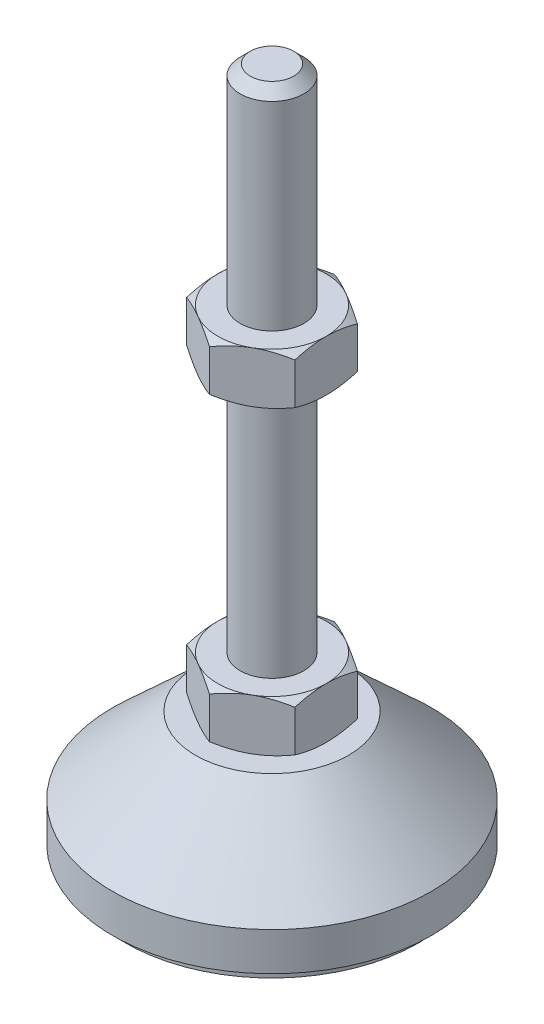
from build123d import *

# Parameters (mm, degrees)
EXTRUDE_1_DEPTH = 8
EXTRUDE_2_DEPTH = 8


with BuildPart() as part:
    # Эскиз1 → Повернуть1 (revolve)
    with BuildSketch(Plane.XY, mode=Mode.PRIVATE) as revolve_1_sk:
        Polygon((0, 0), (-23, 0), (-23, 2), (-25, 2), (-25, 8), (-12, 20), (-5, 20), (-5, 28), (-5, 106.4), (-3.4, 108), (0, 108), align=None)
    revolve(revolve_1_sk.sketch.rotate(Axis((0, 0, 0), (0, 1, 0)), 180), axis=Axis((0, 0, 0), (0, 1, 0)))  # turned: the seam where the file's is

    # Эскиз2 → Бобышка-Вытянуть1 (add)
    with BuildSketch(Plane(origin=(0, 20, 0), x_dir=(1, 0, 0), z_dir=(0, 1, 0))):
        Polygon((0, 9.814954576), (-8.5, 4.907477288), (-8.5, -4.907477288), (0, -9.814954576), (8.5, -4.907477288), (8.5, 4.907477288), align=None)
    extrude(amount=EXTRUDE_1_DEPTH)

    # Эскиз3 → Бобышка-Вытянуть2 (add)
    with BuildSketch(Plane(origin=(0, 67.2, 0), x_dir=(1, 0, 0), z_dir=(0, 1, 0))):
        Polygon((8.5, 4.907477288), (0, 9.814954576), (-8.5, 4.907477288), (-8.5, -4.907477288), (0, -9.814954576), (8.5, -4.907477288), align=None)
    extrude(amount=EXTRUDE_2_DEPTH)

    # Эскиз4 → Вырез-Повернуть2 (revolve, cut)
    with BuildSketch(Plane.XY, mode=Mode.PRIVATE) as cut_revolve_2_sk:
        Polygon((-15.42820323, 75.2), (-8.5, 75.2), (-15.42820323, 71.2), align=None)
        Polygon((-15.42820323, 67.2), (-15.42820323, 71.2), (-8.5, 67.2), align=None)
        Polygon((-15.42820323, 28), (-15.42820323, 24), (-8.5, 28), align=None)
        Polygon((-15.42820323, 24), (-15.42820323, 20), (-8.5, 20), align=None)
    revolve(cut_revolve_2_sk.sketch.rotate(Axis((0, 108, 0), (0, -1, 0)), 180), axis=Axis((0, 108, 0), (0, -1, 0)), mode=Mode.SUBTRACT)  # turned: the seam where the file's is


solid = part.part
